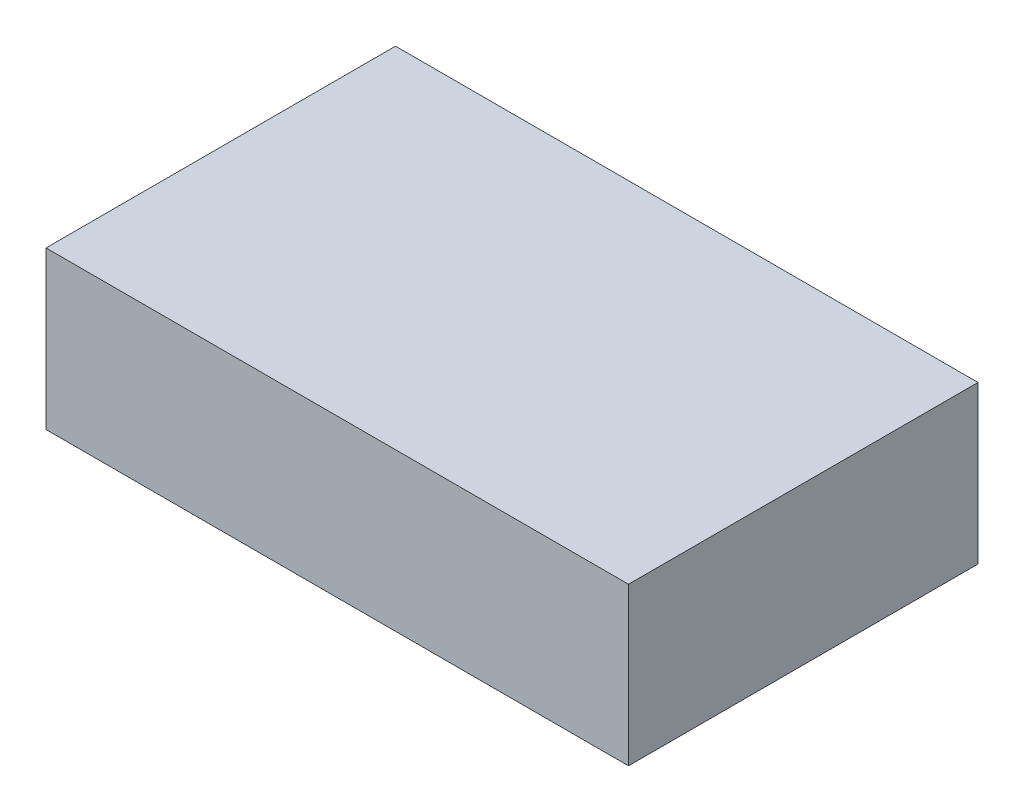
from build123d import *

# Parameters (mm, degrees)
SKETCH1_W           = 10
SKETCH1_H           = 6
BOSS_EXTRUDE1_DEPTH = 2.7


with BuildPart() as part:
    # Sketch1 → Boss-Extrude1 (new body)
    with BuildSketch(Plane(origin=(0, 0, 0), x_dir=(1, 0, 0), z_dir=(0, 1, 0))):
        Rectangle(SKETCH1_W, SKETCH1_H)
    extrude(amount=BOSS_EXTRUDE1_DEPTH)


solid = part.part
